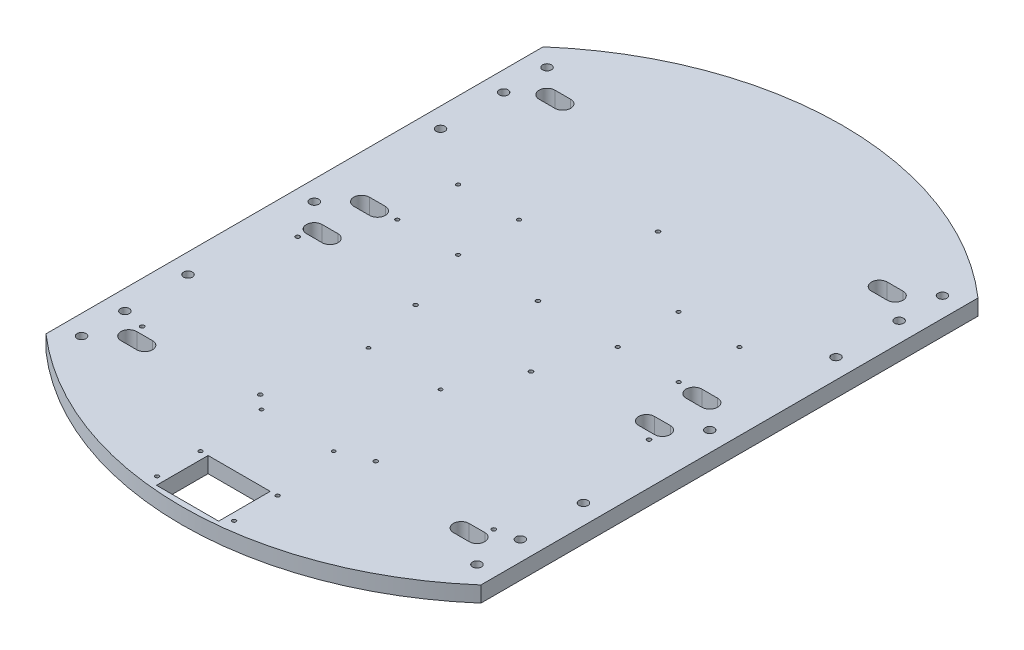
from build123d import *

# Parameters (mm, degrees)
SKETCH1_R           = 1.5
SKETCH1_R_2         = 1.375
SKETCH1_R_3         = 1.6
SKETCH1_R_4         = 1.625
SKETCH1_R_5         = 3.5687
SKETCH1_W           = 50
SKETCH1_H           = 41.5
BOSS_EXTRUDE1_DEPTH = 12.7


with BuildPart() as part:
    # Sketch1 → Boss-Extrude1 (new body)
    with BuildSketch(Plane(origin=(0, 0, 0), x_dir=(1, 0, 0), z_dir=(0, 1, 0))):
        with BuildLine():
            Line((175, -200), (175, 200))
            ThreePointArc((175, 200), (0, 265.753645318), (-175, 200))
            Line((-175, 200), (-175, -200))
            ThreePointArc((-175, -200), (-105.083237909, -244.095295142), (-25, -264.575131106))
            ThreePointArc((-25, -264.575131106), (-12.51388125, -265.458853264), (0, -265.753645318))
            ThreePointArc((0, -265.753645318), (12.51388125, -265.458853264), (25, -264.575131106))
            ThreePointArc((25, -264.575131106), (105.083237909, -244.095295142), (175, -200))
        make_face()
        with Locations((-31, -219.575131106)):
            Circle(SKETCH1_R, mode=Mode.SUBTRACT)
        with Locations((31, -219.575131106)):
            Circle(SKETCH1_R, mode=Mode.SUBTRACT)
        with Locations((22.5, -166)):
            Circle(SKETCH1_R_2, mode=Mode.SUBTRACT)
        with Locations((-31, -254.575131106)):
            Circle(SKETCH1_R, mode=Mode.SUBTRACT)
        with Locations((31, -254.575131106)):
            Circle(SKETCH1_R, mode=Mode.SUBTRACT)
        with Locations((-35.5, -166)):
            Circle(SKETCH1_R_2, mode=Mode.SUBTRACT)
        with Locations((22.5, -80)):
            Circle(SKETCH1_R_2, mode=Mode.SUBTRACT)
        with Locations((-35.5, -80)):
            Circle(SKETCH1_R_2, mode=Mode.SUBTRACT)
        with Locations((0, 117.5)):
            Circle(SKETCH1_R_3, mode=Mode.SUBTRACT)
        with Locations((0, 20.9)):
            Circle(SKETCH1_R_3, mode=Mode.SUBTRACT)
        with Locations((-113.22, 20.9)):
            Circle(SKETCH1_R, mode=Mode.SUBTRACT)
        with Locations((-64.22, 20.9)):
            Circle(SKETCH1_R, mode=Mode.SUBTRACT)
        with Locations((-64.22, 69.81)):
            Circle(SKETCH1_R, mode=Mode.SUBTRACT)
        with Locations((-113.22, 69.81)):
            Circle(SKETCH1_R, mode=Mode.SUBTRACT)
        with Locations((64.22, 20.9)):
            Circle(SKETCH1_R, mode=Mode.SUBTRACT)
        with Locations((113.22, 20.9)):
            Circle(SKETCH1_R, mode=Mode.SUBTRACT)
        with Locations((113.22, 69.81)):
            Circle(SKETCH1_R, mode=Mode.SUBTRACT)
        with Locations((64.22, 69.81)):
            Circle(SKETCH1_R, mode=Mode.SUBTRACT)
        with Locations((-141.42, -31.15)):
            Circle(SKETCH1_R_4, mode=Mode.SUBTRACT)
        with Locations((-46.42, -31.15)):
            Circle(SKETCH1_R_4, mode=Mode.SUBTRACT)
        with Locations((-141.42, -156.15)):
            Circle(SKETCH1_R_4, mode=Mode.SUBTRACT)
        with Locations((-46.42, -156.15)):
            Circle(SKETCH1_R_4, mode=Mode.SUBTRACT)
        with Locations((46.42, -156.15)):
            Circle(SKETCH1_R_4, mode=Mode.SUBTRACT)
        with Locations((141.42, -156.15)):
            Circle(SKETCH1_R_4, mode=Mode.SUBTRACT)
        with Locations((46.42, -31.15)):
            Circle(SKETCH1_R_4, mode=Mode.SUBTRACT)
        with Locations((141.42, -31.15)):
            Circle(SKETCH1_R_4, mode=Mode.SUBTRACT)
        with Locations((-159.12, -101.6)):
            Circle(SKETCH1_R_5, mode=Mode.SUBTRACT)
        with Locations((-159.12, -152.4)):
            Circle(SKETCH1_R_5, mode=Mode.SUBTRACT)
        with Locations((-159.12, 152.4)):
            Circle(SKETCH1_R_5, mode=Mode.SUBTRACT)
        with Locations((-159.12, 101.6)):
            Circle(SKETCH1_R_5, mode=Mode.SUBTRACT)
        with Locations((159.12, -152.4)):
            Circle(SKETCH1_R_5, mode=Mode.SUBTRACT)
        with Locations((159.12, -101.6)):
            Circle(SKETCH1_R_5, mode=Mode.SUBTRACT)
        with Locations((159.12, 101.6)):
            Circle(SKETCH1_R_5, mode=Mode.SUBTRACT)
        with Locations((159.12, 152.4)):
            Circle(SKETCH1_R_5, mode=Mode.SUBTRACT)
        with Locations((-159.12, 187.3)):
            Circle(SKETCH1_R_5, mode=Mode.SUBTRACT)
        with Locations((-159.12, 0)):
            Circle(SKETCH1_R_5, mode=Mode.SUBTRACT)
        with Locations((-159.12, -187.3)):
            Circle(SKETCH1_R_5, mode=Mode.SUBTRACT)
        with Locations((159.12, 187.3)):
            Circle(SKETCH1_R_5, mode=Mode.SUBTRACT)
        with Locations((159.12, 0)):
            Circle(SKETCH1_R_5, mode=Mode.SUBTRACT)
        with Locations((159.12, -187.3)):
            Circle(SKETCH1_R_5, mode=Mode.SUBTRACT)
        with Locations((0, -240.325131106)):
            Rectangle(SKETCH1_W, SKETCH1_H, mode=Mode.SUBTRACT)
        with BuildLine():
            Line((-140.07, -12.7), (-127.37, -12.7))
            ThreePointArc((-127.37, -12.7), (-121.02, -19.05), (-127.37, -25.4))
            Line((-127.37, -25.4), (-140.07, -25.4))
            ThreePointArc((-140.07, -25.4), (-146.42, -19.05), (-140.07, -12.7))
        make_face(mode=Mode.SUBTRACT)
        with BuildLine():
            Line((-140.07, 25.4), (-127.37, 25.4))
            ThreePointArc((-127.37, 25.4), (-121.02, 19.05), (-127.37, 12.7))
            Line((-127.37, 12.7), (-140.07, 12.7))
            ThreePointArc((-140.07, 12.7), (-146.42, 19.05), (-140.07, 25.4))
        make_face(mode=Mode.SUBTRACT)
        with BuildLine():
            Line((140.07, 25.4), (127.37, 25.4))
            ThreePointArc((127.37, 25.4), (121.02, 19.05), (127.37, 12.7))
            Line((127.37, 12.7), (140.07, 12.7))
            ThreePointArc((140.07, 12.7), (146.42, 19.05), (140.07, 25.4))
        make_face(mode=Mode.SUBTRACT)
        with BuildLine():
            Line((140.07, -12.7), (127.37, -12.7))
            ThreePointArc((127.37, -12.7), (121.02, -19.05), (127.37, -25.4))
            Line((127.37, -25.4), (140.07, -25.4))
            ThreePointArc((140.07, -25.4), (146.42, -19.05), (140.07, -12.7))
        make_face(mode=Mode.SUBTRACT)
        with BuildLine():
            Line((-140.07, -161.9), (-127.37, -161.9))
            ThreePointArc((-127.37, -161.9), (-121.02, -168.25), (-127.37, -174.6))
            Line((-127.37, -174.6), (-140.07, -174.6))
            ThreePointArc((-140.07, -174.6), (-146.42, -168.25), (-140.07, -161.9))
        make_face(mode=Mode.SUBTRACT)
        with BuildLine():
            Line((127.37, -161.9), (140.07, -161.9))
            ThreePointArc((140.07, -161.9), (146.42, -168.25), (140.07, -174.6))
            Line((140.07, -174.6), (127.37, -174.6))
            ThreePointArc((127.37, -174.6), (121.02, -168.25), (127.37, -161.9))
        make_face(mode=Mode.SUBTRACT)
        with BuildLine():
            Line((-140.07, 174.6), (-127.37, 174.6))
            ThreePointArc((-127.37, 174.6), (-121.02, 168.25), (-127.37, 161.9))
            Line((-127.37, 161.9), (-140.07, 161.9))
            ThreePointArc((-140.07, 161.9), (-146.42, 168.25), (-140.07, 174.6))
        make_face(mode=Mode.SUBTRACT)
        with BuildLine():
            Line((127.37, 174.6), (140.07, 174.6))
            ThreePointArc((140.07, 174.6), (146.42, 168.25), (140.07, 161.9))
            Line((140.07, 161.9), (127.37, 161.9))
            ThreePointArc((127.37, 161.9), (121.02, 168.25), (127.37, 174.6))
        make_face(mode=Mode.SUBTRACT)
    extrude(amount=BOSS_EXTRUDE1_DEPTH)


solid = part.part
